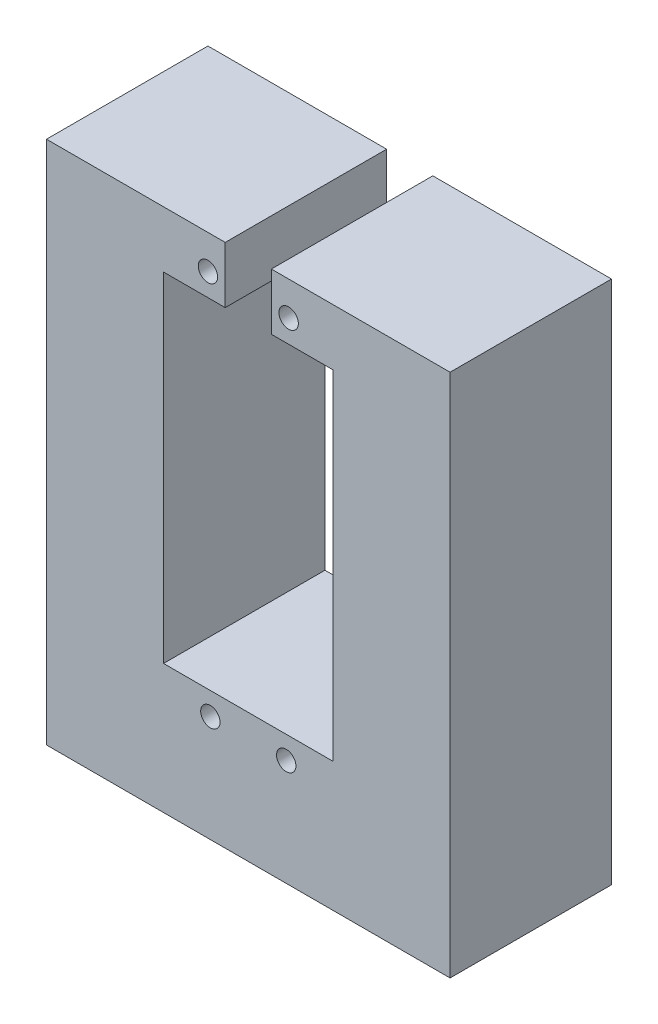
from build123d import *

# Parameters (mm, degrees)
SKETCH_1_W          = 50
SKETCH_1_H          = 65
BOSS_EXTRUDE1_DEPTH = 20
SKETCH11_R          = 1.2
CUT_EXTRUDE1_DEPTH  = 28
SKETCH12_R          = 7
CUT_EXTRUDE2_DEPTH  = 15


with BuildPart() as part:
    # 草圖1 → Boss-Extrude1 (new body)
    with BuildSketch(Plane.XY):
        with Locations((2.083333333, 32.5)):
            Rectangle(SKETCH_1_W, SKETCH_1_H)
    extrude(amount=BOSS_EXTRUDE1_DEPTH)

    # Sketch11 → Cut-Extrude1 (cut)
    with BuildSketch(Plane.XY):
        with Locations((-2.916666667, 60.81)):
            Circle(SKETCH11_R)
        with Locations((-2.616666667, 13.19)):
            Circle(SKETCH11_R)
        with Locations((6.783333333, 13.19)):
            Circle(SKETCH11_R)
        with Locations((7.083333333, 60.81)):
            Circle(SKETCH11_R)
        Polygon((4.942250508, 65), (-0.775583841, 65), (-0.775583841, 58), (-8.416666667, 58), (-8.416666667, 16), (12.583333333, 16), (12.583333333, 58), (4.942250508, 58), align=None)
    extrude(amount=CUT_EXTRUDE1_DEPTH, mode=Mode.SUBTRACT)

    # Sketch12 → Cut-Extrude2 (cut)
    with BuildSketch(Plane(origin=(0, 0, 0), x_dir=(1, 0, 0), z_dir=(0, 1, 0))):
        with Locations((-15.232669486, -9.9188946)):
            Circle(SKETCH12_R)
        with Locations((18.767330514, -9.9188946)):
            Circle(SKETCH12_R)
    extrude(amount=CUT_EXTRUDE2_DEPTH, mode=Mode.SUBTRACT)


solid = part.part
